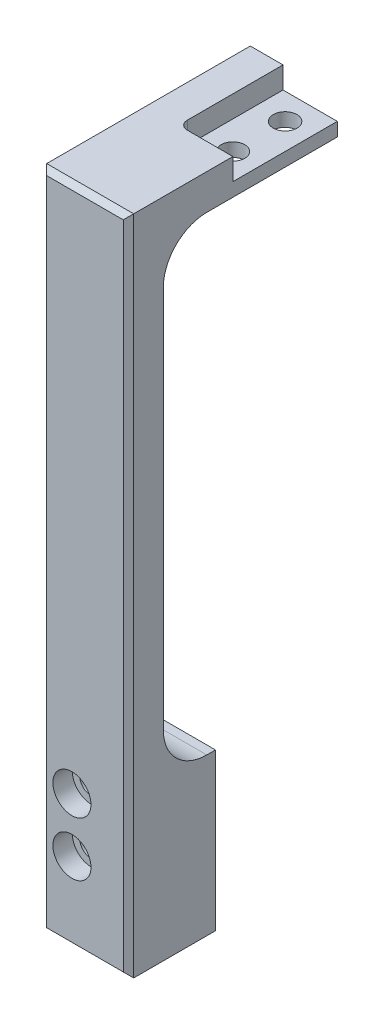
from build123d import *

# Parameters (mm, degrees)
SKETCH1_W                                      = 12.7
SKETCH1_H                                      = 96.5962
EXTRUDE1_DEPTH                                 = 5.08
SKETCH2_W                                      = 12.7
SKETCH2_H                                      = 5.1562
EXTRUDE2_DEPTH                                 = 25.4
SKETCH6_W                                      = 12.7
SKETCH6_H                                      = 22.86
EXTRUDE4_DEPTH                                 = 7.62
F_4_CLEARANCE_HOLE1_D                          = 3.4544
SKETCH7_W                                      = 7.9248
SKETCH7_H                                      = 15.24
EXTRUDE5_DEPTH                                 = 3.175
FILLET1_R                                      = 1.27
FILLET2_R                                      = 6.35
CHAMFER1_SIZE                                  = 0.762
CBORE_FOR_4_SOCKET_HEAD_CAP_SCREW1_D           = 3.4544
CBORE_FOR_4_SOCKET_HEAD_CAP_SCREW1_CBORE_D     = 5.55752
CBORE_FOR_4_SOCKET_HEAD_CAP_SCREW1_CBORE_DEPTH = 2.8448


with BuildPart() as part:
    # Sketch1 → Extrude1 (new body)
    with BuildSketch(Plane.XY):
        with Locations((6.35, -48.2981)):
            Rectangle(SKETCH1_W, SKETCH1_H)
    extrude(amount=EXTRUDE1_DEPTH)

    # Sketch2 → Extrude2 (add)
    with BuildSketch(Plane(origin=(0, 0, 0), x_dir=(-1, 0, 0), z_dir=(0, 0, -1))):
        with Locations((-6.35, -2.5781)):
            Rectangle(SKETCH2_W, SKETCH2_H)
    extrude(amount=EXTRUDE2_DEPTH)

    # Sketch6 → Extrude4 (add)
    with BuildSketch(Plane(origin=(0, 0, 0), x_dir=(-1, 0, 0), z_dir=(0, 0, -1))):
        with Locations((-6.35, -85.1662)):
            Rectangle(SKETCH6_W, SKETCH6_H)
    extrude(amount=EXTRUDE4_DEPTH)

    # #4 Clearance Hole1 (through all)
    with Locations(Plane(origin=(0, 0, 0), x_dir=(-1, 0, 0), z_dir=(0, 1, 0))):
        with Locations((-8.89, -21.59), (-8.89, -13.97)):
            Hole(F_4_CLEARANCE_HOLE1_D / 2)

    # Sketch7 → Extrude5 (cut)
    with BuildSketch(Plane(origin=(0, 0, 0), x_dir=(1, 0, 0), z_dir=(0, 1, 0))):
        with Locations((8.7376, 17.78)):
            Rectangle(SKETCH7_W, SKETCH7_H)
    extrude(amount=-EXTRUDE5_DEPTH, mode=Mode.SUBTRACT)

    # Fillet1
    fillet1_edges = [part.edges().sort_by_distance(p)[0] for p in [
        (4.7752, -1.5875, -10.16),
    ]]
    fillet(fillet1_edges, radius=FILLET1_R)

    # Fillet2
    fillet2_edges = [part.edges().sort_by_distance(p)[0] for p in [
        (6.35, -73.7362, 0),
        (6.35, -5.1562, 0),
    ]]
    fillet(fillet2_edges, radius=FILLET2_R)

    # Chamfer1
    chamfer1_edges = [part.edges().sort_by_distance(p)[0] for p in [
        (12.7, -48.2981, 5.08),
        (6.35, 0, 5.08),
        (0, -48.2981, 5.08),
        (6.35, -96.5962, 5.08),
    ]]
    chamfer(chamfer1_edges, length=CHAMFER1_SIZE)

    # CBORE for #4 Socket Head Cap Screw1 (through all)
    with Locations(Plane.XY.offset(5.08)):
        with Locations((4.445, -84.963), (4.445, -77.0382)):
            CounterBoreHole(CBORE_FOR_4_SOCKET_HEAD_CAP_SCREW1_D / 2, CBORE_FOR_4_SOCKET_HEAD_CAP_SCREW1_CBORE_D / 2, CBORE_FOR_4_SOCKET_HEAD_CAP_SCREW1_CBORE_DEPTH)


solid = part.part
